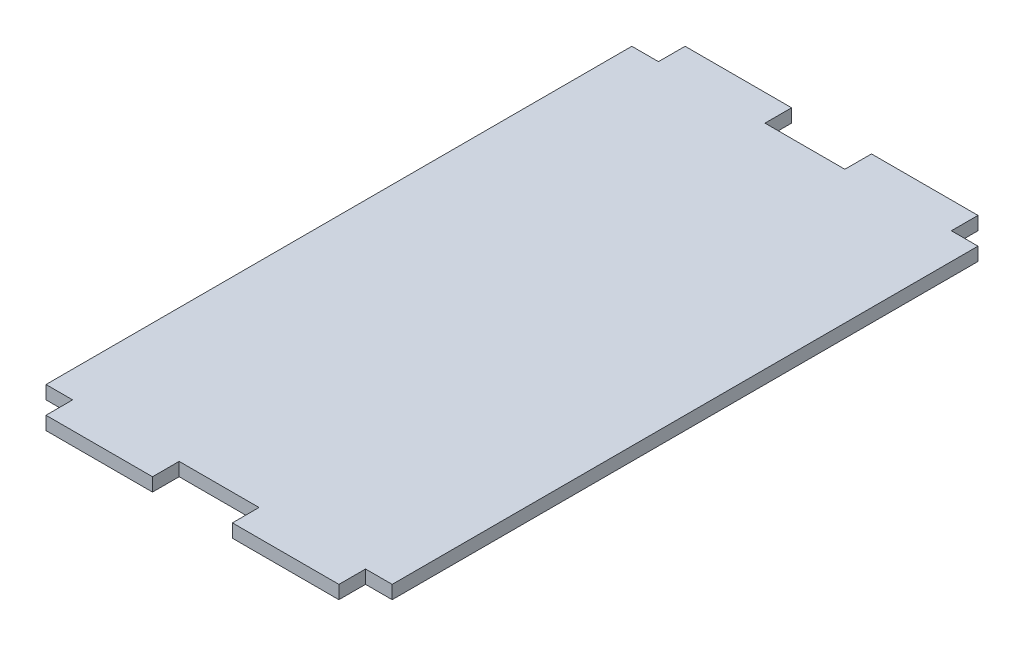
from build123d import *

# Parameters (mm, degrees)
SKETCH1_W           = 82.55
SKETCH1_H           = 152.4
BOSS_EXTRUDE1_DEPTH = 3.175
SKETCH2_W           = 6.35
SKETCH2_H           = 6.35
SKETCH2_W_2         = 9.525
CUT_EXTRUDE1_DEPTH  = 4.175


with BuildPart() as part:
    # Sketch1 → Boss-Extrude1 (new body)
    with BuildSketch(Plane(origin=(0, 0, 0), x_dir=(1, 0, 0), z_dir=(0, 1, 0))):
        Rectangle(SKETCH1_W, SKETCH1_H)
    extrude(amount=BOSS_EXTRUDE1_DEPTH)

    # Sketch2 → Cut-Extrude1 (cut, through all)
    with BuildSketch(Plane(origin=(0, 3.175, 0), x_dir=(1, 0, 0), z_dir=(0, 1, 0))):
        with Locations((-38.1, -73.025)):
            Rectangle(SKETCH2_W, SKETCH2_H)
        with Locations((-4.7625, -73.025)):
            Rectangle(SKETCH2_W_2, SKETCH2_H)
        with Locations((4.7625, -73.025)):
            Rectangle(SKETCH2_W_2, SKETCH2_H)
        with Locations((38.1, -73.025)):
            Rectangle(SKETCH2_W, SKETCH2_H)
    cut_extrude1 = extrude(amount=-CUT_EXTRUDE1_DEPTH, mode=Mode.SUBTRACT)

    # Mirror1: Cut-Extrude1 across plane
    add(cut_extrude1.mirror(Plane.XY), mode=Mode.SUBTRACT)


solid = part.part
